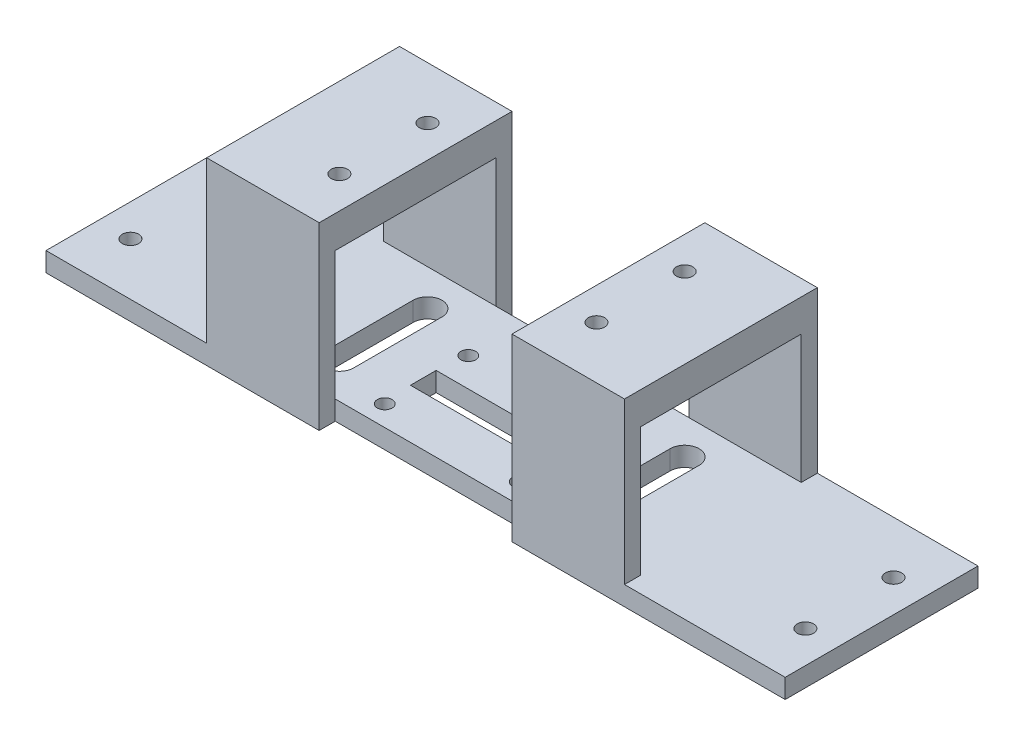
from build123d import *

# Parameters (mm, degrees)
SKETCH1_W                         = 30
SKETCH1_H                         = 25
SKETCH1_R                         = 1.15
SKETCH1_W_2                       = 22
SKETCH1_H_2                       = 4
BOSS_EXTRUDE1_DEPTH               = 3
SKETCH2_W                         = 7.5
SKETCH2_H                         = 20
SKETCH2_R                         = 1.27
BOSS_EXTRUDE2_DEPTH               = 3
SKETCH6_W                         = 20
SKETCH6_H                         = 3
BOSS_EXTRUDE3_DEPTH               = 10
SKETCH7_W                         = 20
SKETCH7_H                         = 3
BOSS_EXTRUDE4_DEPTH               = 10
SKETCH8_W                         = 17.5
SKETCH8_H                         = 20
SKETCH8_R                         = 1.27
BOSS_EXTRUDE5_DEPTH               = 25
SKETCH13_W                        = 17.5
SKETCH13_H                        = 28
BOSS_EXTRUDE6_DEPTH               = 5
SKETCH14_W                        = 17.5
SKETCH14_H                        = 28
BOSS_EXTRUDE7_DEPTH               = 5
SKETCH15_W                        = 25
SKETCH15_H                        = 20
CUT_EXTRUDE2_DEPTH                = 48.5
CUT_EXTRUDE2_DEPTH_BACK           = 18.5
SKETCH16_W                        = 30
SKETCH16_H                        = 3
BOSS_EXTRUDE8_DEPTH               = 25
SKETCH19_W                        = 30
SKETCH19_H                        = 3
BOSS_EXTRUDE9_DEPTH               = 25
F_1_16_0_0625_PRESS_DOWEL_HOLE1_D = 2.54
CUT_EXTRUDE3_DEPTH                = 4


with BuildPart() as part:
    # Sketch1 → Boss-Extrude1 (new body)
    with BuildSketch(Plane(origin=(0, 0, 0), x_dir=(1, 0, 0), z_dir=(0, 1, 0))):
        with Locations((-15, 0)):
            Rectangle(SKETCH1_W, SKETCH1_H)
        with Locations((-4.5, 3.7)):
            Circle(SKETCH1_R, mode=Mode.SUBTRACT)
        with Locations((-4.5, -9.3)):
            Circle(SKETCH1_R, mode=Mode.SUBTRACT)
        with Locations((-25.5, 3.7)):
            Circle(SKETCH1_R, mode=Mode.SUBTRACT)
        with Locations((-25.5, -9.3)):
            Circle(SKETCH1_R, mode=Mode.SUBTRACT)
        with Locations((-15, -2.8)):
            Rectangle(SKETCH1_W_2, SKETCH1_H_2, mode=Mode.SUBTRACT)
    extrude(amount=BOSS_EXTRUDE1_DEPTH)

    # Sketch2 → Boss-Extrude2 (add)
    with BuildSketch(Plane(origin=(0, 3, 0), x_dir=(1, 0, 0), z_dir=(0, 1, 0))):
        with Locations((3.75, 0)):
            Rectangle(SKETCH2_W, SKETCH2_H)
        with Locations((5, 6.858)):
            Circle(SKETCH2_R, mode=Mode.SUBTRACT)
        with Locations((5, -6.858)):
            Circle(SKETCH2_R, mode=Mode.SUBTRACT)
        with Locations((-33.75, 0)):
            Rectangle(SKETCH2_W, SKETCH2_H)
        with Locations((-35, 6.858)):
            Circle(SKETCH2_R, mode=Mode.SUBTRACT)
        with Locations((-35, -6.858)):
            Circle(SKETCH2_R, mode=Mode.SUBTRACT)
    extrude(amount=-BOSS_EXTRUDE2_DEPTH)

    # Sketch6 → Boss-Extrude3 (add)
    with BuildSketch(Plane.ZY.offset(37.5)):
        with Locations((0, 1.5)):
            Rectangle(SKETCH6_W, SKETCH6_H)
    extrude(amount=BOSS_EXTRUDE3_DEPTH)

    # Sketch7 → Boss-Extrude4 (add)
    with BuildSketch(Plane(origin=(7.5, 0, 0), x_dir=(0, 0, -1), z_dir=(1, 0, 0))):
        with Locations((0, 1.5)):
            Rectangle(SKETCH7_W, SKETCH7_H)
    extrude(amount=BOSS_EXTRUDE4_DEPTH)

    # Sketch8 → Boss-Extrude5 (add)
    with BuildSketch(Plane(origin=(0, 3, 0), x_dir=(1, 0, 0), z_dir=(0, 1, 0))):
        with Locations((8.75, 0)):
            Rectangle(SKETCH8_W, SKETCH8_H)
        with Locations((5, 6.858)):
            Circle(SKETCH8_R, mode=Mode.SUBTRACT)
        with Locations((5, -6.858)):
            Circle(SKETCH8_R, mode=Mode.SUBTRACT)
        with Locations((-38.75, 0)):
            Rectangle(SKETCH8_W, SKETCH8_H)
        with Locations((-35, -6.858)):
            Circle(SKETCH8_R, mode=Mode.SUBTRACT)
        with Locations((-35, 6.858)):
            Circle(SKETCH8_R, mode=Mode.SUBTRACT)
    extrude(amount=BOSS_EXTRUDE5_DEPTH)

    # Sketch13 → Boss-Extrude6 (add)
    with BuildSketch(Plane(origin=(0, 0, -10), x_dir=(-1, 0, 0), z_dir=(0, 0, -1))):
        with Locations((38.75, 14)):
            Rectangle(SKETCH13_W, SKETCH13_H)
        with Locations((-8.75, 14)):
            Rectangle(SKETCH13_W, SKETCH13_H)
    extrude(amount=BOSS_EXTRUDE6_DEPTH)

    # Sketch14 → Boss-Extrude7 (add)
    with BuildSketch(Plane.XY.offset(10)):
        with Locations((8.75, 14)):
            Rectangle(SKETCH14_W, SKETCH14_H)
        with Locations((-38.75, 14)):
            Rectangle(SKETCH14_W, SKETCH14_H)
    extrude(amount=BOSS_EXTRUDE7_DEPTH)

    # Sketch15 → Cut-Extrude2 (cut, two sides)
    with BuildSketch(Plane(origin=(-30, 0, 0), x_dir=(0, 0, -1), z_dir=(1, 0, 0))) as cut_extrude2_sk:
        with Locations((0, 13)):
            Rectangle(SKETCH15_W, SKETCH15_H)
    extrude(amount=CUT_EXTRUDE2_DEPTH, mode=Mode.SUBTRACT)
    extrude(cut_extrude2_sk.sketch, amount=-CUT_EXTRUDE2_DEPTH_BACK, mode=Mode.SUBTRACT)

    # Sketch16 → Boss-Extrude8 (add)
    with BuildSketch(Plane.ZY.offset(47.5)):
        with Locations((0, 1.5)):
            Rectangle(SKETCH16_W, SKETCH16_H)
    extrude(amount=BOSS_EXTRUDE8_DEPTH)

    # Sketch19 → Boss-Extrude9 (add)
    with BuildSketch(Plane(origin=(17.5, 0, 0), x_dir=(0, 0, -1), z_dir=(1, 0, 0))):
        with Locations((0, 1.5)):
            Rectangle(SKETCH19_W, SKETCH19_H)
    extrude(amount=BOSS_EXTRUDE9_DEPTH)

    # 1/16 (0.0625) Press Dowel Hole1 (through all)
    with Locations(Plane(origin=(0, 3, 0), x_dir=(1, 0, 0), z_dir=(0, 1, 0))):
        with Locations((-67.5, 6.858), (-67.5, -6.858), (37.5, -6.858), (37.5, 6.858)):
            Hole(F_1_16_0_0625_PRESS_DOWEL_HOLE1_D / 2)

    # Sketch21 → Cut-Extrude3 (cut, through all)
    with BuildSketch(Plane(origin=(0, 3, 0), x_dir=(1, 0, 0), z_dir=(0, 1, 0))):
        with BuildLine():
            Line((2.75, -6.858), (2.75, 6.858))
            ThreePointArc((2.75, 6.858), (5, 9.108), (7.25, 6.858))
            Line((7.25, 6.858), (7.25, -6.858))
            ThreePointArc((7.25, -6.858), (5, -9.108), (2.75, -6.858))
        make_face()
        with BuildLine():
            Line((-32.75, 6.858), (-32.75, -6.858))
            ThreePointArc((-32.75, -6.858), (-35, -9.108), (-37.25, -6.858))
            Line((-37.25, -6.858), (-37.25, 6.858))
            ThreePointArc((-37.25, 6.858), (-35, 9.108), (-32.75, 6.858))
        make_face()
    extrude(amount=-CUT_EXTRUDE3_DEPTH, mode=Mode.SUBTRACT)


solid = part.part
